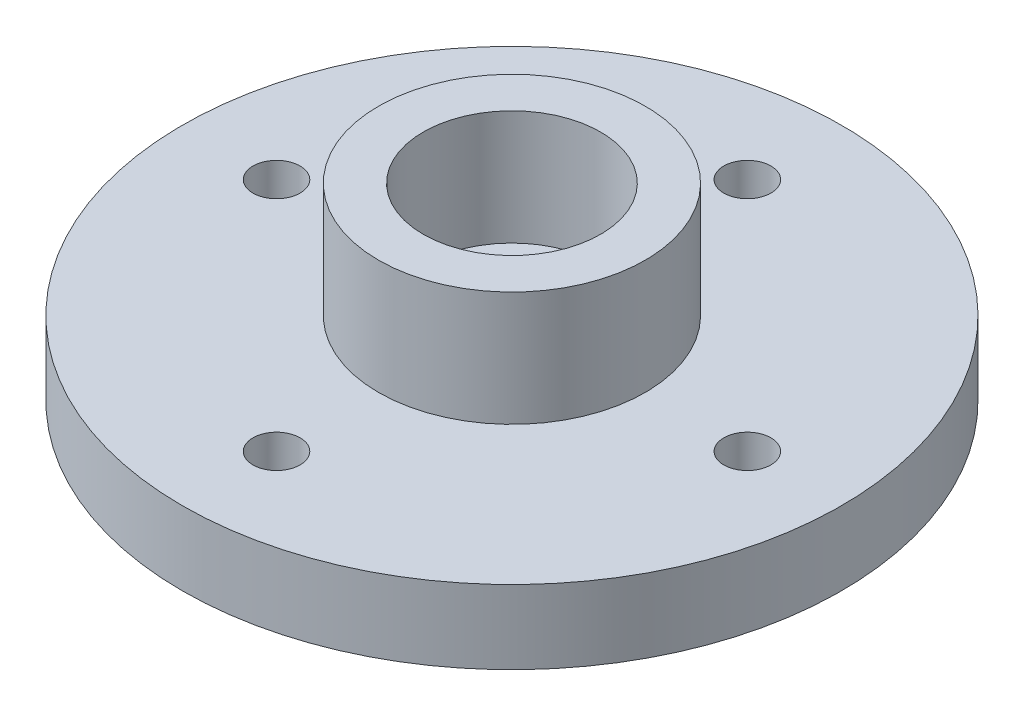
from build123d import *

# Parameters (mm, degrees)
SKETCH1_R           = 10.5
SKETCH1_R_2         = 0.75
SKETCH1_R_3         = 1.5
BOSS_EXTRUDE1_DEPTH = 2.35
BOSS_EXTRUDE2_START = 2.35
SKETCH1_3_R         = 4.25
SKETCH1_3_R_2       = 2.825
BOSS_EXTRUDE2_DEPTH = 3.65


with BuildPart() as part:
    # Sketch1 → Boss-Extrude1 (new body)
    with BuildSketch(Plane(origin=(0, 0, 0), x_dir=(1, 0, 0), z_dir=(0, 1, 0))):
        Circle(SKETCH1_R)
        with Locations((-7.5, 0)):
            Circle(SKETCH1_R_2, mode=Mode.SUBTRACT)
        with Locations((0, 7.5)):
            Circle(SKETCH1_R_2, mode=Mode.SUBTRACT)
        with Locations((7.5, 0)):
            Circle(SKETCH1_R_2, mode=Mode.SUBTRACT)
        with Locations((0, -7.5)):
            Circle(SKETCH1_R_2, mode=Mode.SUBTRACT)
        Circle(SKETCH1_R_3, mode=Mode.SUBTRACT)
    extrude(amount=BOSS_EXTRUDE1_DEPTH)

    # Sketch1_3 → Boss-Extrude2 (add)
    with BuildSketch(Plane(origin=(0, 0, 0), x_dir=(1, 0, 0), z_dir=(0, 1, 0)).offset(BOSS_EXTRUDE2_START)):
        Circle(SKETCH1_3_R)
        Circle(SKETCH1_3_R_2, mode=Mode.SUBTRACT)
    extrude(amount=BOSS_EXTRUDE2_DEPTH)


solid = part.part
